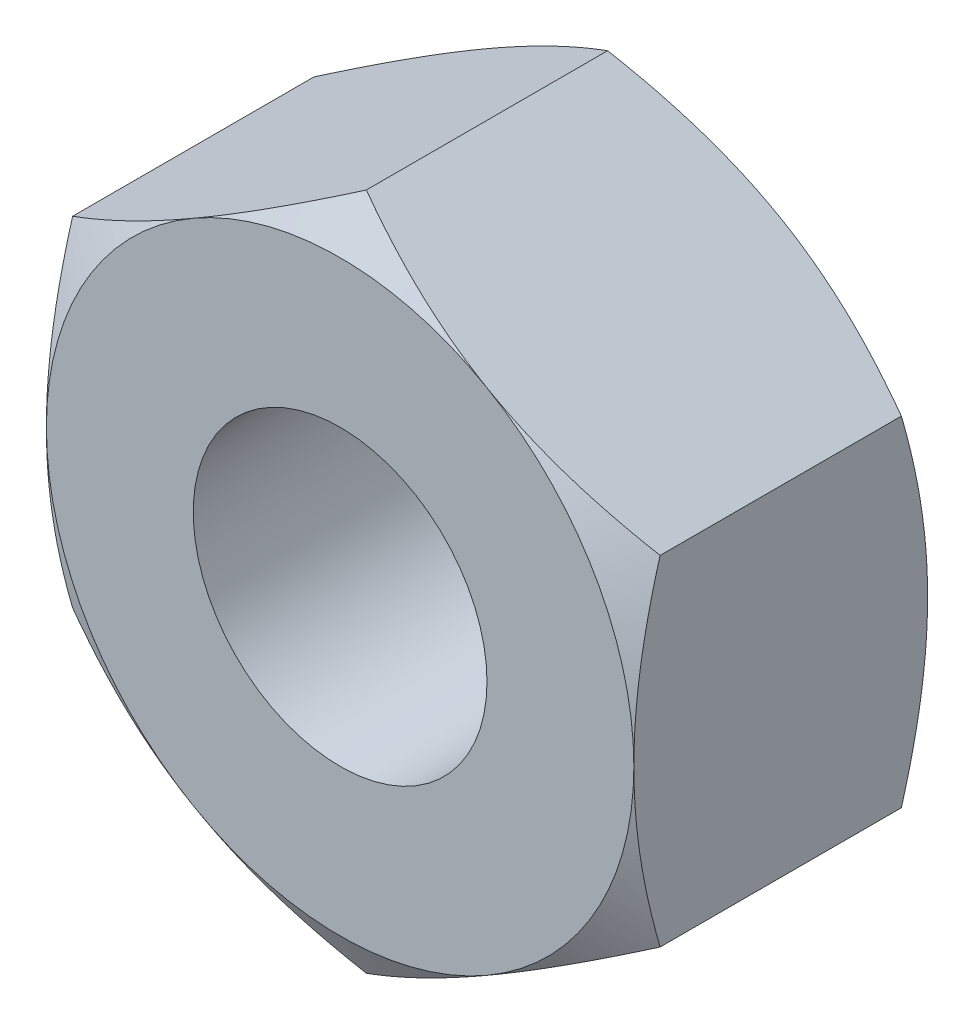
from build123d import *

# Parameters (mm, degrees)
BASENUTSKE_R  = 1
BASENUT_DEPTH = 2


with BuildPart() as part:
    # BaseNutSke → BaseNut (new body)
    with BuildSketch(Plane.XY):
        Polygon((2, 1.154700538), (2, -1.154700538), (0, -2.309401077), (-2, -1.154700538), (-2, 1.154700538), (0, 2.309401077), align=None)
        Circle(BASENUTSKE_R, mode=Mode.SUBTRACT)
    extrude(amount=-BASENUT_DEPTH)

    # Sketch3 → Double-Chamfer (revolve, cut)
    with BuildSketch(Plane(origin=(0, 0, 0), x_dir=(0, 0, -1), z_dir=(1, 0, 0))):
        Polygon((2, 2), (1.821367205, 2.309401077), (1.821367205, 12.309401077), (12, 12.309401077), (12, 2), align=None)
        Polygon((0.178632795, 12.309401077), (-10, 12.309401077), (-10, 2), (0, 2), (0.178632795, 2.309401077), align=None)
    revolve(axis=Axis((0, 0, 0), (0, 0, -1)), mode=Mode.SUBTRACT)


solid = part.part
